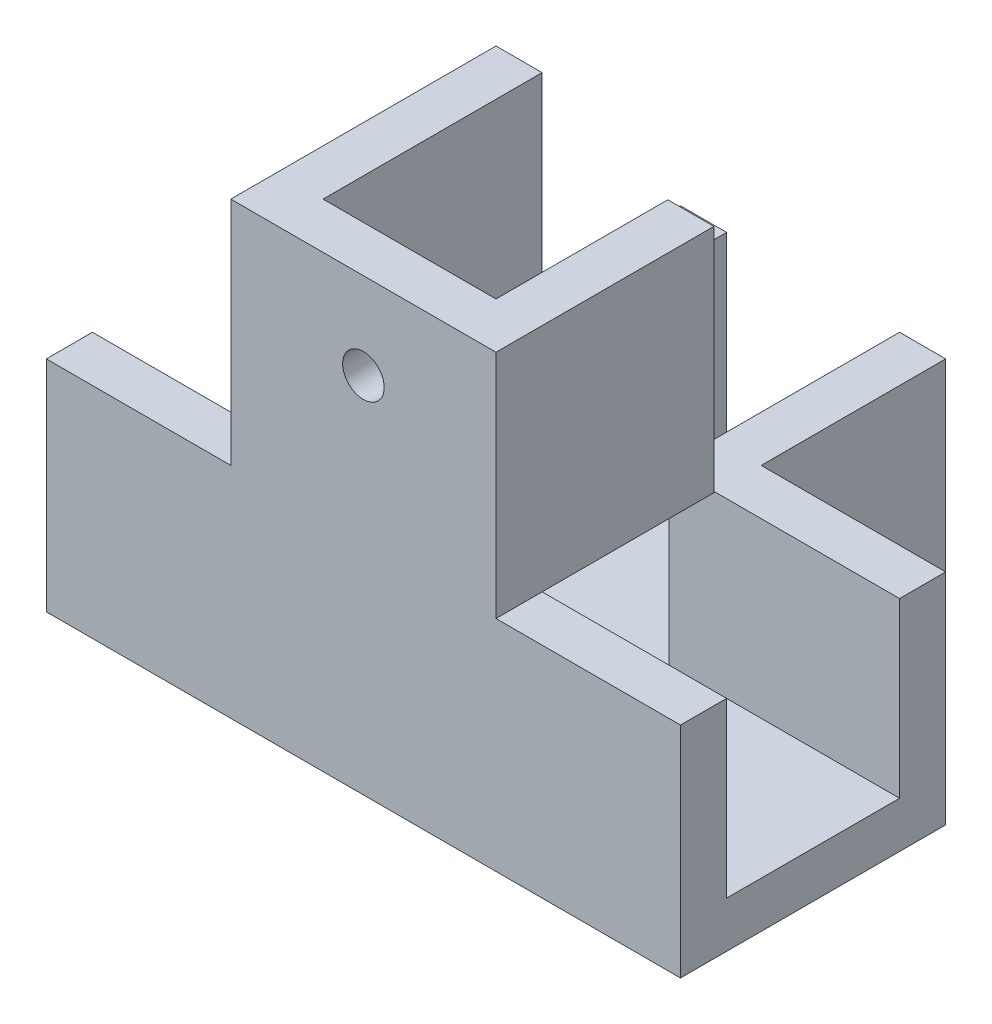
from build123d import *

# Parameters (mm, degrees)
EXTRUDE_1_DEPTH     = 15
EXTRUDE_1_2_DEPTH   = 15
SKETCH_1_W          = 55
SKETCH_1_H          = 4
EXTRUDE_1_3_DEPTH   = 15
EXTRUDE_2_DEPTH     = 4
EXTRUDE_3_DEPTH     = 20
SKETCH_4_R          = 1.8
CUT_EXTRUDE_1_DEPTH = 20
SKETCH_5_R          = 1.8
CUT_EXTRUDE_2_DEPTH = 20


with BuildPart() as part:
    # 草图1 → 凸台-拉伸1 (new body)
    with BuildSketch(Plane(origin=(0, 0, 0), x_dir=(1, 0, 0), z_dir=(0, 1, 0))):
        Polygon((-24.755102041, 11.775510204), (-4.755102041, 11.775510204), (-4.755102041, 31.775510204), (-8.755102041, 31.775510204), (-8.755102041, 15.775510204), (-24.755102041, 15.775510204), align=None)
    extrude(amount=EXTRUDE_1_DEPTH)



with BuildPart() as body_2:
    # 草图1 → Extrude 1 2 (new body)
    with BuildSketch(Plane(origin=(0, 0, 0), x_dir=(1, 0, 0), z_dir=(0, 1, 0))):
        Polygon((30.244897959, 15.775510204), (14.244897959, 15.775510204), (14.244897959, 31.775510204), (10.244897959, 31.775510204), (10.244897959, 11.775510204), (12.244897959, 11.775510204), (30.244897959, 11.775510204), align=None)
    extrude(amount=EXTRUDE_1_2_DEPTH)


with BuildPart() as body_3:
    # 草图1 → Extrude 1 3 (new body)
    with BuildSketch(Plane(origin=(0, 0, 0), x_dir=(1, 0, 0), z_dir=(0, 1, 0))):
        with Locations((2.744897959, -5.224489796)):
            Rectangle(SKETCH_1_W, SKETCH_1_H)
    extrude(amount=EXTRUDE_1_3_DEPTH)


with BuildPart() as part_1:
    add(part.part)

    add(body_2.part)  # 凸台-拉伸2 merges body 2

    add(body_3.part)  # 凸台-拉伸2 merges body 3
    # 草图2 → 凸台-拉伸2 (add)
    with BuildSketch(Plane.XZ):
        Polygon((-8.755102041, -15.775510204), (-24.755102041, -15.775510204), (-24.755102041, 7.224489796), (30.244897959, 7.224489796), (30.244897959, -15.775510204), (14.244897959, -15.775510204), (14.244897959, -31.775510204), (-8.755102041, -31.775510204), align=None)
    extrude(amount=EXTRUDE_2_DEPTH)

    # 草图3 → 凸台-拉伸3 (add)
    with BuildSketch(Plane(origin=(0, 15, 0), x_dir=(1, 0, 0), z_dir=(0, 1, 0))):
        Polygon((-8.755102041, 15.775510204), (-4.755102041, 15.775510204), (-4.755102041, -3.224489796), (10.244897959, -3.224489796), (10.244897959, 11.675510204), (14.244897959, 11.675510204), (14.244897959, -7.224489796), (10.244897959, -7.224489796), (-4.755102041, -7.224489796), (-8.755102041, -7.224489796), align=None)
    extrude(amount=EXTRUDE_3_DEPTH)

    # 草图4 → 切除-拉伸1 (cut)
    with BuildSketch(Plane.XZ.offset(4)):
        with Locations((2.744897959, -24.275510204)):
            Circle(SKETCH_4_R)
        with Locations((2.744897959, -4.275510204)):
            Circle(SKETCH_4_R)
    extrude(amount=-CUT_EXTRUDE_1_DEPTH, mode=Mode.SUBTRACT)

    # 草图5 → 切除-拉伸2 (cut)
    with BuildSketch(Plane.XY.offset(7.224489796)):
        with Locations((2.744897959, 27.5)):
            Circle(SKETCH_5_R)
    extrude(amount=-CUT_EXTRUDE_2_DEPTH, mode=Mode.SUBTRACT)


solid = part_1.part
